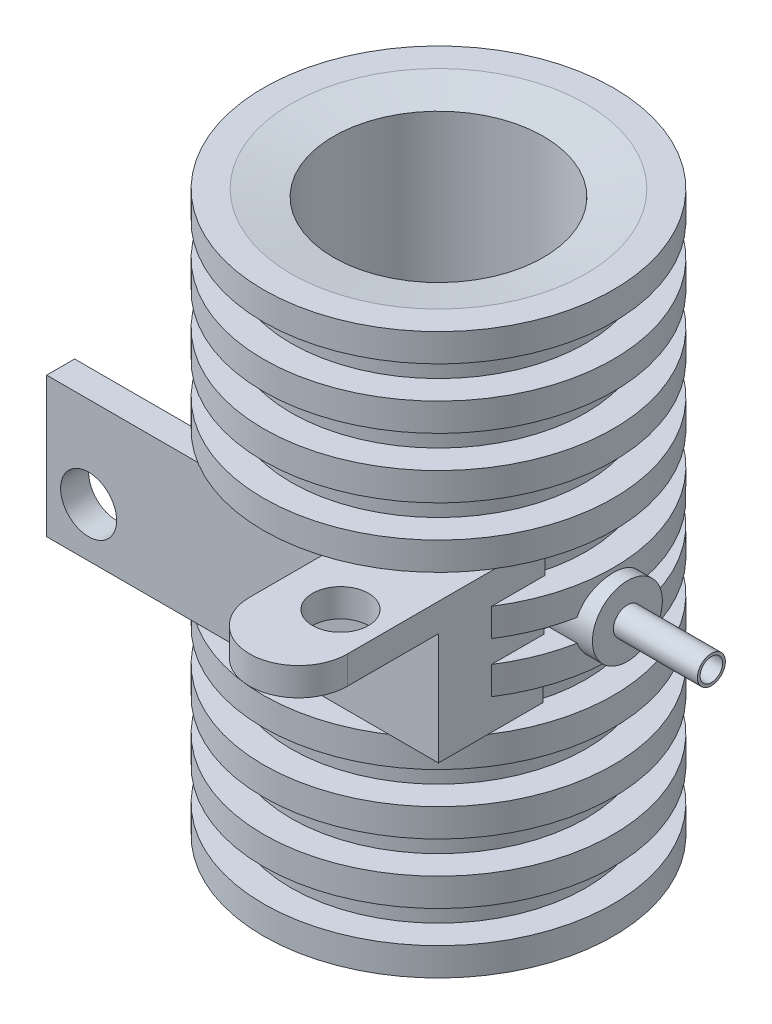
from build123d import *

# Parameters (mm, degrees)
CROQUIS2_R              = 7.5
CORTAR_EXTRUIR1_DEPTH   = 100
CROQUIS3_W              = 6.941059202
CROQUIS3_H              = 10
CROQUIS3_W_2            = 21.058940798
SALIENTE_EXTRUIR1_DEPTH = 2
CROQUIS4_W              = 28
CROQUIS4_H              = 10
CORTAR_EXTRUIR2_DEPTH   = 2
SALIENTE_EXTRUIR2_DEPTH = 2
SALIENTE_EXTRUIR3_DEPTH = 2
CROQUIS8_R              = 2.5
SALIENTE_EXTRUIR4_DEPTH = 19.5
CROQUIS9_R              = 2.5
CROQUIS9_R_2            = 1
CORTAR_EXTRUIR3_DEPTH   = 6
CROQUIS10_R             = 0.803973648
CORTAR_EXTRUIR4_DEPTH   = 16
CROQUIS11_R             = 7.5
CORTAR_EXTRUIR5_DEPTH   = 86
CROQUIS12_R             = 2
CORTAR_EXTRUIR7_DEPTH   = 86
CROQUIS14_R             = 2
CORTAR_EXTRUIR8_DEPTH   = 86
SALIENTE_EXTRUIR5_DEPTH = 1
ESCALA1_SCALE           = 7


with BuildPart() as part:
    # Croquis1 → Revolución2 (revolve)
    with BuildSketch(Plane.XY, mode=Mode.PRIVATE) as revoluci_n2_sk:
        Polygon((-10.529470399, 0), (-7.5, 0.5), (0, 0.5), (0, 39.5), (-7.5, 39.5), (-10.529470399, 40), (-12.5, 40), (-12.5, 38), (-10.529470399, 38), (-10.529470399, 35.7), (-12.5, 35.7), (-12.5, 33.7), (-10.529470399, 33.7), (-10.529470399, 31.4), (-12.5, 31.4), (-12.5, 29.4), (-10.529470399, 29.4), (-10.529470399, 27.1), (-12.5, 27.1), (-12.5, 25.1), (-10.529470399, 25.1), (-10.529470399, 22.8), (-12.5, 22.8), (-12.5, 20.8), (-10.529470399, 20.8), (-10.529470399, 19.2), (-12.5, 19.2), (-12.5, 17.2), (-10.529470399, 17.2), (-10.529470399, 14.9), (-12.5, 14.9), (-12.5, 12.9), (-10.529470399, 12.9), (-10.529470399, 10.6), (-12.5, 10.6), (-12.5, 8.6), (-10.529470399, 8.6), (-10.529470399, 6.3), (-12.5, 6.3), (-12.5, 4.3), (-10.529470399, 4.3), (-10.529470399, 2), (-12.5, 2), (-12.5, 0), align=None)
    revolve(revoluci_n2_sk.sketch.rotate(Axis((0, 0.5, 0), (0, 1, 0)), 270), axis=Axis((0, 0.5, 0), (0, 1, 0)))

    # Croquis2 → Cortar-Extruir1 (cut)
    with BuildSketch(Plane(origin=(0, 39.5, 0), x_dir=(1, 0, 0), z_dir=(0, 1, 0))):
        with Locations(Location((0, 0, 0), (0, 0, 270))):
            Circle(CROQUIS2_R)
    extrude(amount=-CORTAR_EXTRUIR1_DEPTH, mode=Mode.SUBTRACT)

    # Croquis3 → Saliente-Extruir1 (add)
    with BuildSketch(Plane.XY.offset(10.529470399)):
        with Locations((-14, 20)):
            Rectangle(CROQUIS3_W, CROQUIS3_H)
        with Locations((0, 20)):
            Rectangle(CROQUIS3_W_2, CROQUIS3_H)
    extrude(amount=-SALIENTE_EXTRUIR1_DEPTH)

    # Croquis4 → Cortar-Extruir2 (cut)
    with BuildSketch(Plane.XY.offset(10.529470399)):
        with Locations((-3.470529601, 20)):
            Rectangle(CROQUIS4_W, CROQUIS4_H)
    extrude(amount=CORTAR_EXTRUIR2_DEPTH, mode=Mode.SUBTRACT)

    # Croquis5 → Saliente-Extruir2 (add)
    with BuildSketch(Plane(origin=(10.529470399, 0, 0), x_dir=(0, 0, -1), z_dir=(1, 0, 0))):
        Polygon((-8.529470399, 25), (-2.889330359, 25), (-3.068508508, 15), (-8.411275116, 15), (-8.529470399, 15), align=None)
    extrude(amount=-SALIENTE_EXTRUIR2_DEPTH)

    # Croquis7 → Saliente-Extruir3 (add)
    with BuildSketch(Plane(origin=(0, 25, 0), x_dir=(1, 0, 0), z_dir=(0, 1, 0))):
        with BuildLine():
            Line((10.529470399, -10.529470399), (10.529470399, -17.029470399))
            ThreePointArc((10.529470399, -17.029470399), (7.029470399, -20.529470399), (3.529470399, -17.029470399))
            Line((3.529470399, -17.029470399), (3.529470399, -10.529470399))
            Line((3.529470399, -10.529470399), (10.529470399, -10.529470399))
        make_face()
    extrude(amount=-SALIENTE_EXTRUIR3_DEPTH)

    # Croquis8 → Saliente-Extruir4 (add)
    with BuildSketch(Plane(origin=(0, 0, 0), x_dir=(0, 0, -1), z_dir=(1, 0, 0))):
        with Locations(Location((0, 20, 0), (0, 0, 161.337082109))):
            Circle(CROQUIS8_R)
    extrude(amount=SALIENTE_EXTRUIR4_DEPTH)

    # Croquis9 → Cortar-Extruir3 (cut)
    with BuildSketch(Plane(origin=(19.5, 0, 0), x_dir=(0, 0, -1), z_dir=(1, 0, 0))):
        with Locations(Location((0, 20, 0), (0, 0, 161.337082109))):
            Circle(CROQUIS9_R)
        with Locations((0, 20)):
            Circle(CROQUIS9_R_2, mode=Mode.SUBTRACT)
    extrude(amount=-CORTAR_EXTRUIR3_DEPTH, mode=Mode.SUBTRACT)

    # Croquis10 → Cortar-Extruir4 (cut)
    with BuildSketch(Plane(origin=(19.5, 0, 0), x_dir=(0, 0, -1), z_dir=(1, 0, 0))):
        with Locations((0, 20)):
            Circle(CROQUIS10_R)
    extrude(amount=-CORTAR_EXTRUIR4_DEPTH, mode=Mode.SUBTRACT)

    # Croquis11 → Cortar-Extruir5 (cut)
    with BuildSketch(Plane(origin=(0, 40, 0), x_dir=(1, 0, 0), z_dir=(0, 1, 0))):
        with Locations(Location((0, 0, 0), (0, 0, 270))):
            Circle(CROQUIS11_R)
    extrude(amount=-CORTAR_EXTRUIR5_DEPTH, mode=Mode.SUBTRACT)

    # Croquis12 → Cortar-Extruir7 (cut)
    with BuildSketch(Plane.XY.offset(10.529470399)):
        with Locations((-14.470529601, 18.5)):
            Circle(CROQUIS12_R)
    extrude(amount=-CORTAR_EXTRUIR7_DEPTH, mode=Mode.SUBTRACT)

    # Croquis14 → Cortar-Extruir8 (cut)
    with BuildSketch(Plane.XZ.offset(-23)):
        with Locations(Location((7.529470399, 14.529470399, 0), (0, 0, 270))):
            Circle(CROQUIS14_R)
    extrude(amount=-CORTAR_EXTRUIR8_DEPTH, mode=Mode.SUBTRACT)

    # Croquis15 → Saliente-Extruir5 (add)
    with BuildSketch(Plane(origin=(0, 20, 0), x_dir=(-1, 0, 0), z_dir=(0, -1, 0))):
        with BuildLine():
            Line((-6.835484568, -3.086446293), (-6.835484568, 3.086446293))
            ThreePointArc((-6.835484568, 3.086446293), (-7.5, 0), (-6.835484568, -3.086446293))
        make_face()
    extrude(amount=-SALIENTE_EXTRUIR5_DEPTH)


with BuildPart() as part_1:
    # Escala1: scaled about (0.011645774, 20.045435338, 0.404795785)
    add(part.part.scale(ESCALA1_SCALE).moved(Location((-0.069874644, -120.272612028, -2.42877471))))


solid = part_1.part
